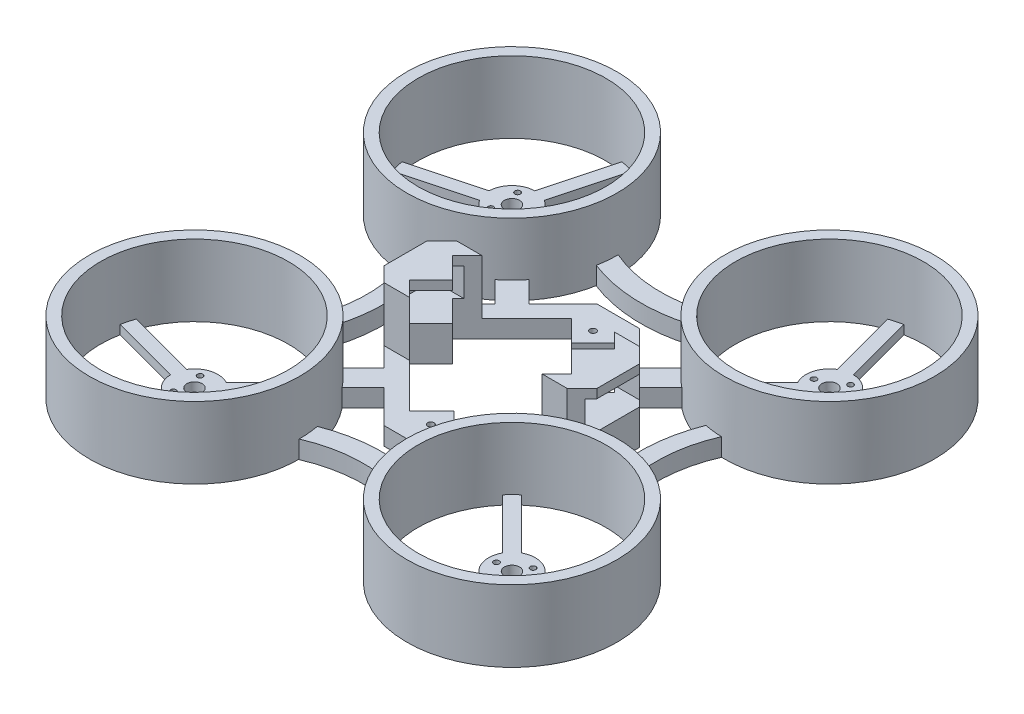
from build123d import *

# Parameters (mm, degrees)
SKETCH2_15_R            = 0.625
SKETCH2_15_R_2          = 1.7
BOSS_EXTRUDE4_DEPTH     = 2
BOSS_EXTRUDE4_2_DEPTH   = 2
BOSS_EXTRUDE4_3_DEPTH   = 2
BOSS_EXTRUDE4_4_DEPTH   = 2
SKETCH2_R               = 23.5
SKETCH2_R_2             = 21
BOSS_EXTRUDE5_DEPTH     = 16
SKETCH2_21_R            = 0.7
BOSS_EXTRUDE8_DEPTH     = 4
BOSS_EXTRUDE10_DEPTH    = 12.2
CUT_EXTRUDE2_DEPTH      = 25.2
CUT_EXTRUDE2_DEPTH_BACK = 25.2
SKETCH19_W              = 12.2
SKETCH19_H              = 6.35


with BuildPart() as part:
    # Sketch2_15 → Boss-Extrude4 (new body)
    with BuildSketch(Plane(origin=(0, 0, 0), x_dir=(1, 0, 0), z_dir=(0, 1, 0))):
        with BuildLine():
            ThreePointArc((28.625166762, -55.337193701), (30.060172465, -55.777234467), (31.522944241, -56.113650836))
            Line((31.522944241, -56.113650836), (35.642313805, -40.739954327))
            ThreePointArc((35.642313805, -40.739954327), (39.207130962, -39.204550664), (40.742534625, -35.639733508))
            Line((40.742534625, -35.639733508), (56.116231134, -31.520363943))
            ThreePointArc((56.116231134, -31.520363943), (55.779814764, -30.057592167), (55.339773999, -28.622586464))
            Line((55.339773999, -28.622586464), (39.966077489, -32.741956029))
            ThreePointArc((39.966077489, -32.741956029), (36.852590984, -30.422066249), (32.996534359, -30.876504489))
            Line((32.996534359, -30.876504489), (21.742645486, -19.622615616))
            ThreePointArc((21.742645486, -19.622615616), (20.644988433, -20.644691372), (19.623081465, -21.742505568))
            Line((19.623081465, -21.742505568), (30.877485921, -32.996910024))
            ThreePointArc((30.877485921, -32.996910024), (30.425081267, -36.851633813), (32.744536326, -39.963497192))
            Line((32.744536326, -39.963497192), (28.625166762, -55.337193701))
        make_face()
        with Locations((37.225275692, -32.495078076)):
            Circle(SKETCH2_15_R, mode=Mode.SUBTRACT)
        with Locations((37.225275692, -38.495078084)):
            Circle(SKETCH2_15_R, mode=Mode.SUBTRACT)
        with Locations((32.029123262, -35.49507808)):
            Circle(SKETCH2_15_R, mode=Mode.SUBTRACT)
        with Locations((35.495372412, -35.492792114)):
            Circle(SKETCH2_15_R_2, mode=Mode.SUBTRACT)
    extrude(amount=BOSS_EXTRUDE4_DEPTH)



with BuildPart() as body_2:
    # Sketch2_15 → Boss-Extrude4 2 (new body)
    with BuildSketch(Plane(origin=(0, 0, 0), x_dir=(1, 0, 0), z_dir=(0, 1, 0))):
        with BuildLine():
            Line((39.966077489, 32.741956029), (55.339773999, 28.622586464))
            ThreePointArc((55.339773999, 28.622586464), (55.779814764, 30.057592167), (56.116231134, 31.520363943))
            Line((56.116231134, 31.520363943), (40.742534625, 35.639733508))
            ThreePointArc((40.742534625, 35.639733508), (39.207130962, 39.204550664), (35.642313805, 40.739954327))
            Line((35.642313805, 40.739954327), (31.522944241, 56.113650836))
            ThreePointArc((31.522944241, 56.113650836), (30.060172465, 55.777234467), (28.625166762, 55.337193701))
            Line((28.625166762, 55.337193701), (32.744536326, 39.963497192))
            ThreePointArc((32.744536326, 39.963497192), (30.425081267, 36.851633813), (30.877485921, 32.996910024))
            Line((30.877485921, 32.996910024), (19.623081465, 21.742505568))
            ThreePointArc((19.623081465, 21.742505568), (20.644988433, 20.644691372), (21.742645486, 19.622615616))
            Line((21.742645486, 19.622615616), (32.996534359, 30.876504489))
            ThreePointArc((32.996534359, 30.876504489), (36.852590984, 30.422066249), (39.966077489, 32.741956029))
        make_face()
        with Locations((37.225275692, 32.495078076)):
            Circle(SKETCH2_15_R, mode=Mode.SUBTRACT)
        with Locations((37.225275692, 38.495078084)):
            Circle(SKETCH2_15_R, mode=Mode.SUBTRACT)
        with Locations((32.029123262, 35.49507808)):
            Circle(SKETCH2_15_R, mode=Mode.SUBTRACT)
        with Locations((35.495372412, 35.492792114)):
            Circle(SKETCH2_15_R_2, mode=Mode.SUBTRACT)
    extrude(amount=BOSS_EXTRUDE4_2_DEPTH)


with BuildPart() as body_3:
    # Sketch2_15 → Boss-Extrude4 3 (new body)
    with BuildSketch(Plane(origin=(0, 0, 0), x_dir=(1, 0, 0), z_dir=(0, 1, 0))):
        with BuildLine():
            ThreePointArc((-31.522944241, -56.113650836), (-30.060172465, -55.777234467), (-28.625166762, -55.337193701))
            Line((-28.625166762, -55.337193701), (-32.744536326, -39.963497192))
            ThreePointArc((-32.744536326, -39.963497192), (-30.425081267, -36.851633813), (-30.877485921, -32.996910024))
            Line((-30.877485921, -32.996910024), (-19.623081465, -21.742505568))
            ThreePointArc((-19.623081465, -21.742505568), (-20.644988433, -20.644691372), (-21.742645486, -19.622615616))
            Line((-21.742645486, -19.622615616), (-32.996534359, -30.876504489))
            ThreePointArc((-32.996534359, -30.876504489), (-36.852590984, -30.422066249), (-39.966077489, -32.741956029))
            Line((-39.966077489, -32.741956029), (-55.339773999, -28.622586464))
            ThreePointArc((-55.339773999, -28.622586464), (-55.779814764, -30.057592167), (-56.116231134, -31.520363943))
            Line((-56.116231134, -31.520363943), (-40.742534625, -35.639733508))
            ThreePointArc((-40.742534625, -35.639733508), (-39.207130962, -39.204550664), (-35.642313805, -40.739954327))
            Line((-35.642313805, -40.739954327), (-31.522944241, -56.113650836))
        make_face()
        with Locations((-32.029123262, -35.49507808)):
            Circle(SKETCH2_15_R, mode=Mode.SUBTRACT)
        with Locations((-37.225275692, -38.495078084)):
            Circle(SKETCH2_15_R, mode=Mode.SUBTRACT)
        with Locations((-37.225275692, -32.495078076)):
            Circle(SKETCH2_15_R, mode=Mode.SUBTRACT)
        with Locations((-35.495372412, -35.492792114)):
            Circle(SKETCH2_15_R_2, mode=Mode.SUBTRACT)
    extrude(amount=BOSS_EXTRUDE4_3_DEPTH)


with BuildPart() as body_4:
    # Sketch2_15 → Boss-Extrude4 4 (new body)
    with BuildSketch(Plane(origin=(0, 0, 0), x_dir=(1, 0, 0), z_dir=(0, 1, 0))):
        with BuildLine():
            ThreePointArc((-28.625166762, 55.337193701), (-30.060172465, 55.777234467), (-31.522944241, 56.113650836))
            Line((-31.522944241, 56.113650836), (-35.642313805, 40.739954327))
            ThreePointArc((-35.642313805, 40.739954327), (-39.207130962, 39.204550664), (-40.742534625, 35.639733508))
            Line((-40.742534625, 35.639733508), (-56.116231134, 31.520363943))
            ThreePointArc((-56.116231134, 31.520363943), (-55.779814764, 30.057592167), (-55.339773999, 28.622586464))
            Line((-55.339773999, 28.622586464), (-39.966077489, 32.741956029))
            ThreePointArc((-39.966077489, 32.741956029), (-36.852590984, 30.422066249), (-32.996534359, 30.876504489))
            Line((-32.996534359, 30.876504489), (-21.742645486, 19.622615616))
            ThreePointArc((-21.742645486, 19.622615616), (-20.644988433, 20.644691372), (-19.623081465, 21.742505568))
            Line((-19.623081465, 21.742505568), (-30.877485921, 32.996910024))
            ThreePointArc((-30.877485921, 32.996910024), (-30.425081267, 36.851633813), (-32.744536326, 39.963497192))
            Line((-32.744536326, 39.963497192), (-28.625166762, 55.337193701))
        make_face()
        with Locations((-37.225275692, 38.495078084)):
            Circle(SKETCH2_15_R, mode=Mode.SUBTRACT)
        with Locations((-37.225275692, 32.495078076)):
            Circle(SKETCH2_15_R, mode=Mode.SUBTRACT)
        with Locations((-35.495372412, 35.492792114)):
            Circle(SKETCH2_15_R_2, mode=Mode.SUBTRACT)
        with Locations((-32.029123262, 35.49507808)):
            Circle(SKETCH2_15_R, mode=Mode.SUBTRACT)
    extrude(amount=BOSS_EXTRUDE4_4_DEPTH)


with BuildPart() as part_1:
    add(part.part)

    add(body_2.part)  # Boss-Extrude5 merges body 2

    add(body_3.part)  # Boss-Extrude5 merges body 3

    add(body_4.part)  # Boss-Extrude5 merges body 4
    # Sketch2 → Boss-Extrude5 (add)
    # profile 1 of 4: a face of its own
    with BuildSketch(Plane(origin=(0, 0, 0), x_dir=(1, 0, 0), z_dir=(0, 1, 0))):
        with Locations((35.495372412, 35.492792114)):
            Circle(SKETCH2_R)
        with Locations((35.495372412, 35.492792114)):
            Circle(SKETCH2_R_2, mode=Mode.SUBTRACT)
    # profile 2 of 4: a face of its own
    with BuildSketch(Plane(origin=(0, 0, 0), x_dir=(1, 0, 0), z_dir=(0, 1, 0))):
        with Locations((35.495372412, -35.492792114)):
            Circle(SKETCH2_R)
        with Locations((35.495372412, -35.492792114)):
            Circle(SKETCH2_R_2, mode=Mode.SUBTRACT)
    # profile 3 of 4: a face of its own
    with BuildSketch(Plane(origin=(0, 0, 0), x_dir=(1, 0, 0), z_dir=(0, 1, 0))):
        with Locations((-35.495372412, 35.492792114)):
            Circle(SKETCH2_R)
        with Locations((-35.495372412, 35.492792114)):
            Circle(SKETCH2_R_2, mode=Mode.SUBTRACT)
    # profile 4 of 4: a face of its own
    with BuildSketch(Plane(origin=(0, 0, 0), x_dir=(1, 0, 0), z_dir=(0, 1, 0))):
        with Locations((-35.495372412, -35.492792114)):
            Circle(SKETCH2_R)
        with Locations((-35.495372412, -35.492792114)):
            Circle(SKETCH2_R_2, mode=Mode.SUBTRACT)
    extrude(amount=BOSS_EXTRUDE5_DEPTH)

    # Sketch2_21 → Boss-Extrude8 (add)
    # profile 1 of 5: a face of its own
    with BuildSketch(Plane(origin=(0, 0, 0), x_dir=(1, 0, 0), z_dir=(0, 1, 0))):
        with BuildLine():
            Line((23.776294655, -4.781895039), (23.776294655, 4.781895039))
            Line((23.776294655, 4.781895039), (16.163638548, 12.394551146))
            Line((16.163638548, 12.394551146), (20.868678779, 17.099591377))
            ThreePointArc((20.868678779, 17.099591377), (18.87613209, 18.878014021), (17.098244576, 20.871038205))
            Line((17.098244576, 20.871038205), (12.392698033, 16.165491661))
            Line((12.392698033, 16.165491661), (4.780041841, 23.778147853))
            Line((4.780041841, 23.778147853), (-4.780041841, 23.778147853))
            Line((-4.780041841, 23.778147853), (-12.392698033, 16.165491661))
            Line((-12.392698033, 16.165491661), (-17.098244576, 20.871038205))
            ThreePointArc((-17.098244576, 20.871038205), (-18.87613209, 18.878014021), (-20.868678779, 17.099591377))
            Line((-20.868678779, 17.099591377), (-16.163638548, 12.394551146))
            Line((-16.163638548, 12.394551146), (-23.776294655, 4.781895039))
            Line((-23.776294655, 4.781895039), (-23.776294655, -4.781895039))
            Line((-23.776294655, -4.781895039), (-16.163638548, -12.394551146))
            Line((-16.163638548, -12.394551146), (-20.868678779, -17.099591377))
            ThreePointArc((-20.868678779, -17.099591377), (-18.87613209, -18.878014021), (-17.098244576, -20.871038205))
            Line((-17.098244576, -20.871038205), (-12.392698033, -16.165491661))
            Line((-12.392698033, -16.165491661), (-4.992173875, -23.566015819))
            Line((-4.992173875, -23.566015819), (4.992173875, -23.566015819))
            Line((4.992173875, -23.566015819), (12.392698033, -16.165491661))
            Line((12.392698033, -16.165491661), (17.098244576, -20.871038205))
            ThreePointArc((17.098244576, -20.871038205), (18.87613209, -18.878014021), (20.868678779, -17.099591377))
            Line((20.868678779, -17.099591377), (16.163638548, -12.394551146))
            Line((16.163638548, -12.394551146), (23.776294655, -4.781895039))
        make_face()
        with Locations((0, -18.121293604)):
            Circle(SKETCH2_21_R, mode=Mode.SUBTRACT)
        with Locations((-18.123146802, 0.001853198)):
            Circle(SKETCH2_21_R, mode=Mode.SUBTRACT)
        Polygon((-18.123146802, 4.781895039), (-4.780041841, 18.125), (0, 13.344958159), (4.780041841, 18.125), (18.123146802, 4.781895039), (13.343104961, 0.001853198), (18.123146802, -4.778188643), (4.992173875, -17.909161569), (0, -12.916987694), (-4.992173875, -17.909161569), (-18.123146802, -4.778188643), (-13.343104961, 0.001853198), align=None, mode=Mode.SUBTRACT)
        with Locations((18.123146802, 0.001853198)):
            Circle(SKETCH2_21_R, mode=Mode.SUBTRACT)
        with Locations((0, 18.125)):
            Circle(SKETCH2_21_R, mode=Mode.SUBTRACT)
    # profile 2 of 5: a face of its own
    with BuildSketch(Plane(origin=(0, 0, 0), x_dir=(1, 0, 0), z_dir=(0, 1, 0))):
        with BuildLine():
            ThreePointArc((34.842081674, 12.001874482), (32.870564007, 12.139839821), (30.917610908, 12.442974336))
            ThreePointArc((30.917610908, 12.442974336), (28.543422286, 0), (30.917610908, -12.442974336))
            ThreePointArc((30.917610908, -12.442974336), (32.870564007, -12.139839821), (34.842081674, -12.001874482))
            ThreePointArc((34.842081674, -12.001874482), (32.336736444, 0), (34.842081674, 12.001874482))
        make_face()
    # profile 3 of 5: a face of its own
    with BuildSketch(Plane(origin=(0, 0, 0), x_dir=(1, 0, 0), z_dir=(0, 1, 0))):
        with BuildLine():
            ThreePointArc((-30.917610908, -12.442974336), (-28.543422286, 0), (-30.917610908, 12.442974336))
            ThreePointArc((-30.917610908, 12.442974336), (-32.870564007, 12.139839821), (-34.842081674, 12.001874482))
            ThreePointArc((-34.842081674, 12.001874482), (-32.336736444, 0), (-34.842081674, -12.001874482))
            ThreePointArc((-34.842081674, -12.001874482), (-32.870564007, -12.139839821), (-30.917610908, -12.442974336))
        make_face()
    # profile 4 of 5: a face of its own
    with BuildSketch(Plane(origin=(0, 0, 0), x_dir=(1, 0, 0), z_dir=(0, 1, 0))):
        with BuildLine():
            ThreePointArc((12.362058797, 31.199612618), (12.057031332, 33.437127643), (11.967914548, 35.693579158))
            ThreePointArc((11.967914548, 35.693579158), (0.022036632, 33.203022385), (-11.92748729, 35.676026681))
            ThreePointArc((-11.92748729, 35.676026681), (-12.018023221, 33.420870549), (-12.323854283, 31.18471463))
            ThreePointArc((-12.323854283, 31.18471463), (0.020503262, 28.870704154), (12.362058797, 31.199612618))
        make_face()
    # profile 5 of 5: a face of its own
    with BuildSketch(Plane(origin=(0, 0, 0), x_dir=(1, 0, 0), z_dir=(0, 1, 0))):
        with BuildLine():
            ThreePointArc((-12.323854283, -31.18471463), (-12.018023221, -33.420870549), (-11.92748729, -35.676026681))
            ThreePointArc((-11.92748729, -35.676026681), (0.022036632, -33.203022385), (11.967914548, -35.693579158))
            ThreePointArc((11.967914548, -35.693579158), (12.057031332, -33.437127643), (12.362058797, -31.199612618))
            ThreePointArc((12.362058797, -31.199612618), (0.020503262, -28.870704154), (-12.323854283, -31.18471463))
        make_face()
    extrude(amount=BOSS_EXTRUDE8_DEPTH)

    # Sketch20 → Boss-Extrude10 (add)
    with BuildSketch(Plane(origin=(0, 4, 0), x_dir=(1, 0, 0), z_dir=(0, 1, 0))):
        Polygon((-20.458189694, 8.1), (-14.805041841, 8.1), (-18.123146802, 4.781895039), (-13.343104961, 0.001853198), (-18.123146802, -4.778188643), (-14.801335444, -8.1), (-20.458189694, -8.1), (-23.776294655, -4.781895039), (-23.776294655, 4.781895039), align=None)
        Polygon((20.458189694, -8.1), (14.801335444, -8.1), (18.123146802, -4.778188643), (13.343104961, 0.001853198), (18.123146802, 4.781895039), (14.805041841, 8.1), (20.458189694, 8.1), (23.776294655, 4.781895039), (23.776294655, -4.781895039), align=None)
    extrude(amount=BOSS_EXTRUDE10_DEPTH)

    # Sketch19 → Cut-Extrude2 (cut, two sides: drawn at the far end of the back side and taken through both)
    with BuildSketch(Plane(origin=(0, 0, 0), x_dir=(0, 0, -1), z_dir=(1, 0, 0)).offset(-CUT_EXTRUDE2_DEPTH_BACK)):
        with Locations((0.001853198, 11.025)):
            Rectangle(SKETCH19_W, SKETCH19_H)
    extrude(amount=CUT_EXTRUDE2_DEPTH + CUT_EXTRUDE2_DEPTH_BACK, mode=Mode.SUBTRACT)


solid = part_1.part
